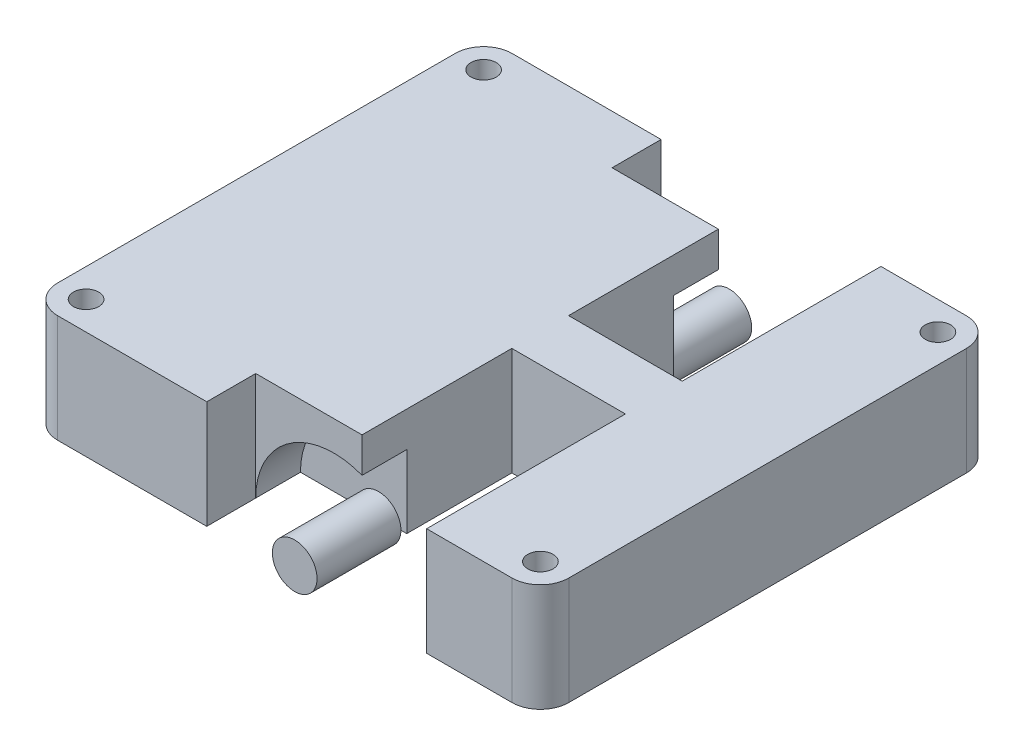
from build123d import *

# Parameters (mm, degrees)
SKETCH1_W             = 45.72
SKETCH1_H             = 40.64
BODY_DEPTH            = 4.826
CORNER_FILLET_R       = 2.54
F_4_40_TAPPED_HOLE1_D = 2.2606
SKETCH4_W             = 13.97
SKETCH4_H             = 9.652
WHEEL_CUTOUT_DEPTH    = 8.382
SKETCH5_R             = 2
WHEEL_SHAFT_DEPTH     = 7.5
SKETCH9_W             = 10.16
SKETCH9_H             = 9.652
CUT_EXTRUDE2_DEPTH    = 17.78
BOSS_EXTRUDE2_DEPTH   = 4


with BuildPart() as part:
    # Sketch1 → Body (new body, symmetric)
    with BuildSketch(Plane(origin=(0, 0, 0), x_dir=(1, 0, 0), z_dir=(0, 1, 0))):
        Rectangle(SKETCH1_W, SKETCH1_H)
    extrude(amount=BODY_DEPTH, both=True)

    # Corner Fillet
    corner_fillet_edges = [part.edges().sort_by_distance(p)[0] for p in [
        (22.86, 0, 20.32),
        (-22.86, 0, 20.32),
        (-22.86, 0, -20.32),
        (22.86, 0, -20.32),
    ]]
    fillet(corner_fillet_edges, radius=CORNER_FILLET_R)

    # #4-40 Tapped Hole1 (through all)
    with Locations(Plane(origin=(0, 4.826, 0), x_dir=(1, 0, 0), z_dir=(0, 1, 0))):
        with Locations((20.32, 17.78), (-20.32, -17.78), (-20.32, 17.78), (20.32, -17.78)):
            Hole(F_4_40_TAPPED_HOLE1_D / 2)

    # Sketch4 → Wheel Cutout (cut)
    with BuildSketch(Plane(origin=(0, 0, -20.32), x_dir=(-1, 0, 0), z_dir=(0, 0, -1))):
        Rectangle(SKETCH4_W, SKETCH4_H)
    wheel_cutout = extrude(amount=-WHEEL_CUTOUT_DEPTH, mode=Mode.SUBTRACT)

    # Sketch5 → Wheel Shaft (add)
    with BuildSketch(Plane(origin=(0, 0, -11.938), x_dir=(-1, 0, 0), z_dir=(0, 0, -1))):
        with Locations((0, -4.826)):
            Circle(SKETCH5_R)
    wheel_shaft = extrude(amount=WHEEL_SHAFT_DEPTH)

    # Sketch9 → Cut-Extrude2 (cut)
    with BuildSketch(Plane(origin=(0, 0, -20.32), x_dir=(-1, 0, 0), z_dir=(0, 0, -1))):
        with Locations((-7.603288762, 0)):
            Rectangle(SKETCH9_W, SKETCH9_H)
    cut_extrude2 = extrude(amount=-CUT_EXTRUDE2_DEPTH, mode=Mode.SUBTRACT)

    # Sketch10 → Boss-Extrude2 (add)
    with BuildSketch(Plane(origin=(0, 0, -11.938), x_dir=(-1, 0, 0), z_dir=(0, 0, -1))):
        with BuildLine():
            Line((6.985, 4.826), (-2.523288762, 4.826))
            Line((-2.523288762, 4.826), (-2.523288762, 1.687312431))
            ThreePointArc((-2.523288762, 1.687312431), (3.947470899, 0.936612125), (6.985, -4.826))
            Line((6.985, -4.826), (6.985, 4.826))
        make_face()
    boss_extrude2 = extrude(amount=BOSS_EXTRUDE2_DEPTH)

    # Mirror3: Wheel Cutout, Wheel Shaft, Cut-Extrude2, Boss-Extrude2 across plane
    add(wheel_cutout.mirror(Plane.XY), mode=Mode.SUBTRACT)
    add(wheel_shaft.mirror(Plane.XY))
    add(cut_extrude2.mirror(Plane.XY), mode=Mode.SUBTRACT)
    add(boss_extrude2.mirror(Plane.XY))


solid = part.part
